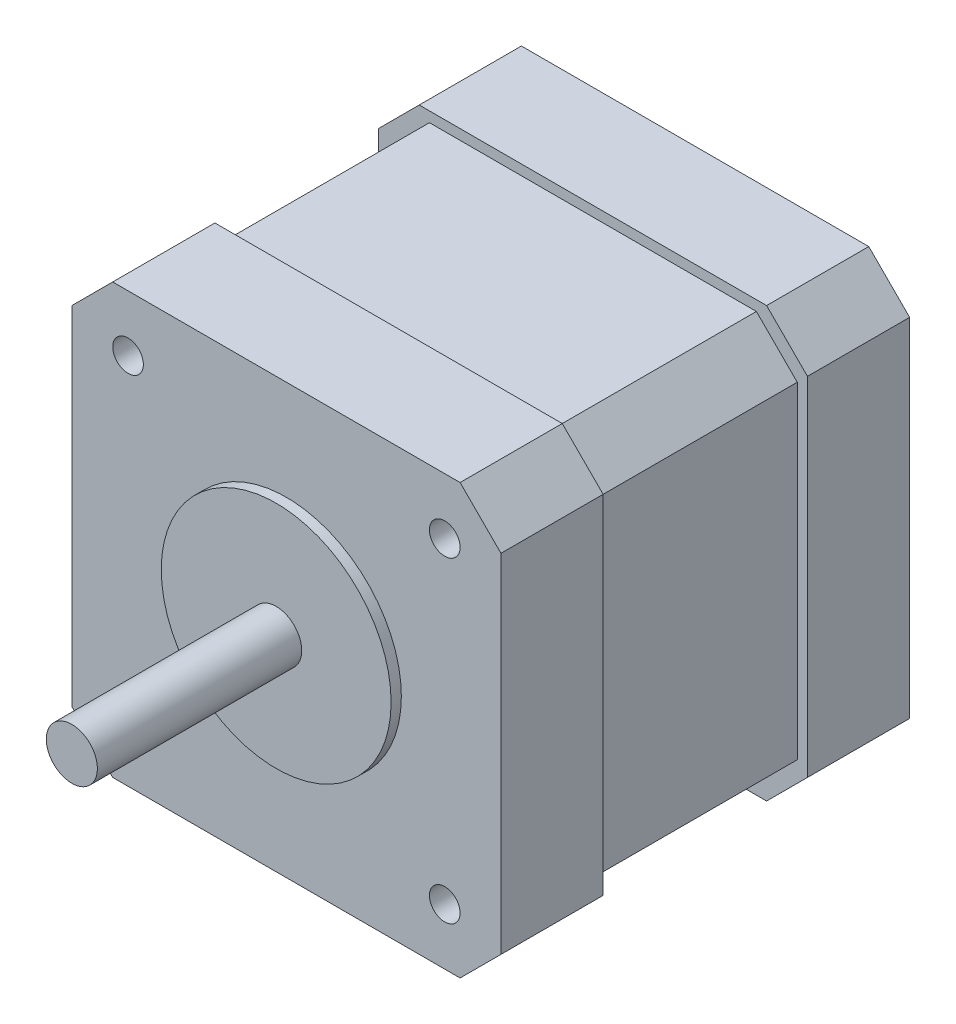
from build123d import *

# Parameters (mm, degrees)
SKETCH1_W           = 42
SKETCH1_H           = 42
BOSS_EXTRUDE1_DEPTH = 10
SKETCH2_W           = 40
SKETCH2_H           = 40
BOSS_EXTRUDE2_DEPTH = 20
SKETCH3_W           = 42
SKETCH3_H           = 42
BOSS_EXTRUDE3_DEPTH = 10
SKETCH4_R           = 11.25
BOSS_EXTRUDE4_DEPTH = 1
CHAMFER1_SIZE       = 4
SKETCH5_R           = 2.5
BOSS_EXTRUDE5_DEPTH = 20
SKETCH6_R           = 1.5
CUT_EXTRUDE1_DEPTH  = 40


with BuildPart() as part:
    # Sketch1 → Boss-Extrude1 (new body)
    with BuildSketch(Plane.XY):
        Rectangle(SKETCH1_W, SKETCH1_H)
    extrude(amount=BOSS_EXTRUDE1_DEPTH)

    # Sketch2 → Boss-Extrude2 (add)
    with BuildSketch(Plane.XY.offset(10)):
        Rectangle(SKETCH2_W, SKETCH2_H)
    extrude(amount=BOSS_EXTRUDE2_DEPTH)

    # Sketch3 → Boss-Extrude3 (add)
    with BuildSketch(Plane.XY.offset(30)):
        Rectangle(SKETCH3_W, SKETCH3_H)
    extrude(amount=BOSS_EXTRUDE3_DEPTH)

    # Sketch4 → Boss-Extrude4 (add)
    with BuildSketch(Plane.XY.offset(40)):
        Circle(SKETCH4_R)
    extrude(amount=BOSS_EXTRUDE4_DEPTH)

    # Chamfer1
    chamfer1_edges = [part.edges().sort_by_distance(p)[0] for p in [
        (20, -20, 20),
        (20, 20, 20),
        (-20, 20, 20),
        (-20, -20, 20),
        (21, -21, 35),
        (21, 21, 35),
        (-21, 21, 35),
        (-21, -21, 35),
        (21, -21, 5),
        (-21, -21, 5),
        (-21, 21, 5),
        (21, 21, 5),
    ]]
    chamfer(chamfer1_edges, length=CHAMFER1_SIZE)

    # Sketch5 → Boss-Extrude5 (add)
    with BuildSketch(Plane.XY.offset(41)):
        Circle(SKETCH5_R)
    extrude(amount=BOSS_EXTRUDE5_DEPTH)

    # Sketch6 → Cut-Extrude1 (cut)
    with BuildSketch(Plane.XY.offset(40)):
        with Locations((-15.5, -15.5)):
            Circle(SKETCH6_R)
        with Locations((-15.5, 15.5)):
            Circle(SKETCH6_R)
        with Locations((15.5, 15.5)):
            Circle(SKETCH6_R)
        with Locations((15.5, -15.5)):
            Circle(SKETCH6_R)
    extrude(amount=-CUT_EXTRUDE1_DEPTH, mode=Mode.SUBTRACT)


solid = part.part
